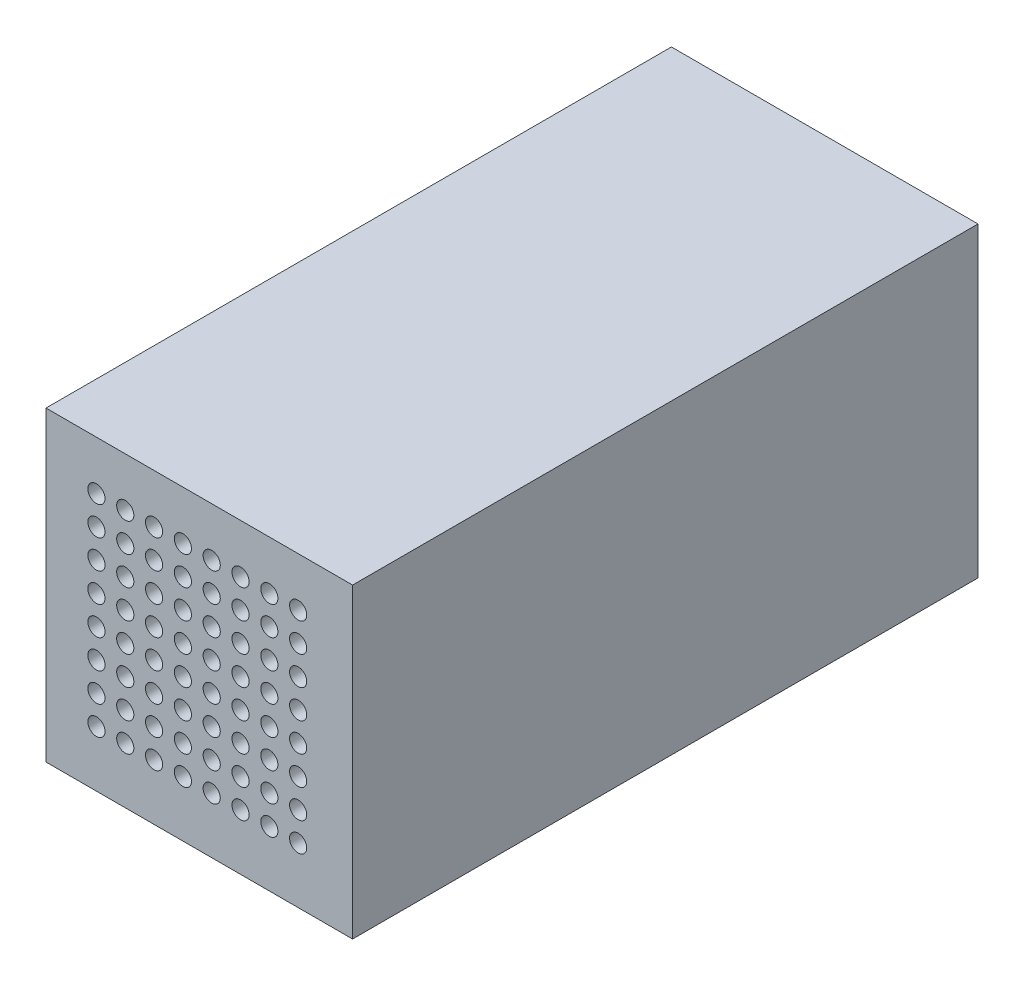
from build123d import *

# Parameters (mm, degrees)
SKETCH2_W           = 25
SKETCH2_H           = 25
BOSS_EXTRUDE1_DEPTH = 8
SKETCH5_R           = 0.7
CUT_EXTRUDE2_DEPTH  = 8
SKETCH2_6_W         = 25
SKETCH2_6_H         = 25
SKETCH2_6_W_2       = 20
SKETCH2_6_H_2       = 20
BOSS_EXTRUDE2_DEPTH = 43


with BuildPart() as part:
    # Sketch2 → Boss-Extrude1 (new body)
    with BuildSketch(Plane.XY.offset(43)):
        Rectangle(SKETCH2_W, SKETCH2_H)
    extrude(amount=BOSS_EXTRUDE1_DEPTH)

    # Sketch5 → Cut-Extrude2 (cut)
    with BuildSketch(Plane.XY.offset(43)):
        with Locations((-8.388056057, 8.509622087)):
            Circle(SKETCH5_R)
        with Locations((-6.038056057, 8.509622087)):
            Circle(SKETCH5_R)
        with Locations((-3.688056057, 8.509622087)):
            Circle(SKETCH5_R)
        with Locations((-1.338056057, 8.509622087)):
            Circle(SKETCH5_R)
        with Locations((1.011943943, 8.509622087)):
            Circle(SKETCH5_R)
        with Locations((3.361943943, 8.509622087)):
            Circle(SKETCH5_R)
        with Locations((5.711943943, 8.509622087)):
            Circle(SKETCH5_R)
        with Locations((8.061943943, 8.509622087)):
            Circle(SKETCH5_R)
        with Locations((-6.038056057, 6.159622087)):
            Circle(SKETCH5_R)
        with Locations((-3.688056057, 6.159622087)):
            Circle(SKETCH5_R)
        with Locations((-1.338056057, 6.159622087)):
            Circle(SKETCH5_R)
        with Locations((1.011943943, 6.159622087)):
            Circle(SKETCH5_R)
        with Locations((3.361943943, 6.159622087)):
            Circle(SKETCH5_R)
        with Locations((5.711943943, 6.159622087)):
            Circle(SKETCH5_R)
        with Locations((8.061943943, 6.159622087)):
            Circle(SKETCH5_R)
        with Locations((-6.038056057, 3.809622087)):
            Circle(SKETCH5_R)
        with Locations((-3.688056057, 3.809622087)):
            Circle(SKETCH5_R)
        with Locations((-1.338056057, 3.809622087)):
            Circle(SKETCH5_R)
        with Locations((1.011943943, 3.809622087)):
            Circle(SKETCH5_R)
        with Locations((3.361943943, 3.809622087)):
            Circle(SKETCH5_R)
        with Locations((5.711943943, 3.809622087)):
            Circle(SKETCH5_R)
        with Locations((8.061943943, 3.809622087)):
            Circle(SKETCH5_R)
        with Locations((-6.038056057, 1.459622087)):
            Circle(SKETCH5_R)
        with Locations((-3.688056057, 1.459622087)):
            Circle(SKETCH5_R)
        with Locations((-1.338056057, 1.459622087)):
            Circle(SKETCH5_R)
        with Locations((1.011943943, 1.459622087)):
            Circle(SKETCH5_R)
        with Locations((3.361943943, 1.459622087)):
            Circle(SKETCH5_R)
        with Locations((5.711943943, 1.459622087)):
            Circle(SKETCH5_R)
        with Locations((8.061943943, 1.459622087)):
            Circle(SKETCH5_R)
        with Locations((-6.038056057, -0.890377913)):
            Circle(SKETCH5_R)
        with Locations((-3.688056057, -0.890377913)):
            Circle(SKETCH5_R)
        with Locations((-1.338056057, -0.890377913)):
            Circle(SKETCH5_R)
        with Locations((1.011943943, -0.890377913)):
            Circle(SKETCH5_R)
        with Locations((3.361943943, -0.890377913)):
            Circle(SKETCH5_R)
        with Locations((5.711943943, -0.890377913)):
            Circle(SKETCH5_R)
        with Locations((8.061943943, -0.890377913)):
            Circle(SKETCH5_R)
        with Locations((-6.038056057, -3.240377913)):
            Circle(SKETCH5_R)
        with Locations((-3.688056057, -3.240377913)):
            Circle(SKETCH5_R)
        with Locations((-1.338056057, -3.240377913)):
            Circle(SKETCH5_R)
        with Locations((1.011943943, -3.240377913)):
            Circle(SKETCH5_R)
        with Locations((3.361943943, -3.240377913)):
            Circle(SKETCH5_R)
        with Locations((5.711943943, -3.240377913)):
            Circle(SKETCH5_R)
        with Locations((8.061943943, -3.240377913)):
            Circle(SKETCH5_R)
        with Locations((-6.038056057, -5.590377913)):
            Circle(SKETCH5_R)
        with Locations((-3.688056057, -5.590377913)):
            Circle(SKETCH5_R)
        with Locations((-1.338056057, -5.590377913)):
            Circle(SKETCH5_R)
        with Locations((1.011943943, -5.590377913)):
            Circle(SKETCH5_R)
        with Locations((3.361943943, -5.590377913)):
            Circle(SKETCH5_R)
        with Locations((5.711943943, -5.590377913)):
            Circle(SKETCH5_R)
        with Locations((8.061943943, -5.590377913)):
            Circle(SKETCH5_R)
        with Locations((-6.038056057, -7.940377913)):
            Circle(SKETCH5_R)
        with Locations((-3.688056057, -7.940377913)):
            Circle(SKETCH5_R)
        with Locations((-1.338056057, -7.940377913)):
            Circle(SKETCH5_R)
        with Locations((1.011943943, -7.940377913)):
            Circle(SKETCH5_R)
        with Locations((3.361943943, -7.940377913)):
            Circle(SKETCH5_R)
        with Locations((5.711943943, -7.940377913)):
            Circle(SKETCH5_R)
        with Locations((8.061943943, -7.940377913)):
            Circle(SKETCH5_R)
        with Locations((-8.388056057, 6.159622087)):
            Circle(SKETCH5_R)
        with Locations((-8.388056057, 3.809622087)):
            Circle(SKETCH5_R)
        with Locations((-8.388056057, 1.459622087)):
            Circle(SKETCH5_R)
        with Locations((-8.388056057, -0.890377913)):
            Circle(SKETCH5_R)
        with Locations((-8.388056057, -3.240377913)):
            Circle(SKETCH5_R)
        with Locations((-8.388056057, -5.590377913)):
            Circle(SKETCH5_R)
        with Locations((-8.388056057, -7.940377913)):
            Circle(SKETCH5_R)
    extrude(amount=CUT_EXTRUDE2_DEPTH, mode=Mode.SUBTRACT)

    # Sketch2_6 → Boss-Extrude2 (add)
    with BuildSketch(Plane.XY.offset(43)):
        Rectangle(SKETCH2_6_W, SKETCH2_6_H)
        Rectangle(SKETCH2_6_W_2, SKETCH2_6_H_2, mode=Mode.SUBTRACT)
    extrude(amount=-BOSS_EXTRUDE2_DEPTH)


solid = part.part
